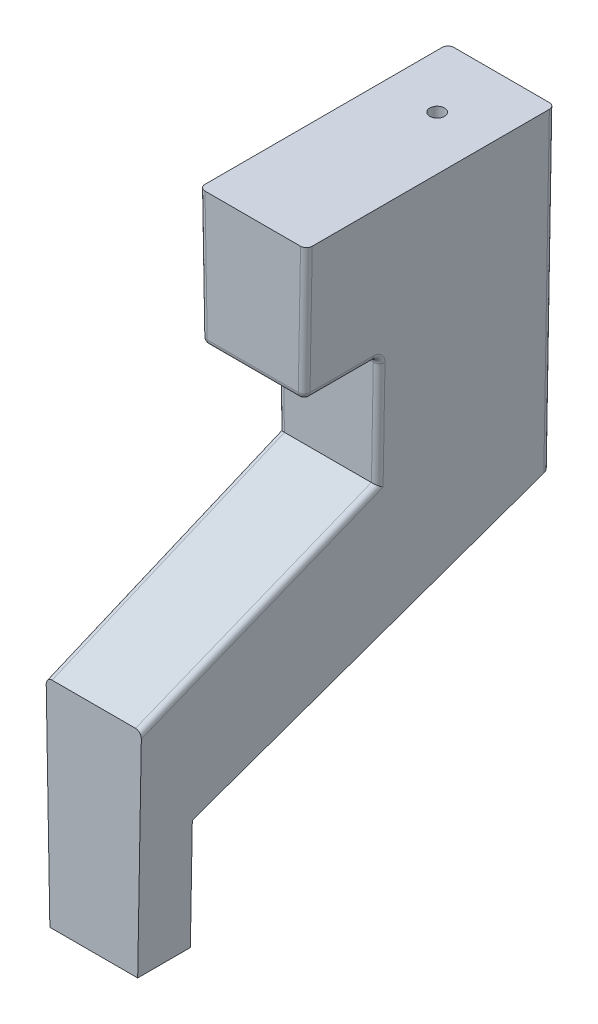
from build123d import *

# Parameters (mm, degrees)
BOSS_EXTRUDE1_DEPTH = 1.5
DRAFT4_ANGLE        = -1
FILLET1_R           = 0.1
SKETCH5_R           = 0.125
CUT_EXTRUDE1_DEPTH  = 2.5


with BuildPart() as part:
    # Sketch1 → Boss-Extrude1 (new body)
    with BuildSketch(Plane(origin=(0, 0, 0), x_dir=(0, 0, -1), z_dir=(1, 0, 0))):
        Polygon((0.9, 1.9), (0.9, 0), (0, 0), (0, 3.674994058), (4, 5.325119328), (4, 7.218922126), (2.71583546, 7.218922126), (2.71583546, 9.5), (6.966077176, 9.5), (6.966077176, 4.107871531), align=None)
    extrude(amount=BOSS_EXTRUDE1_DEPTH)

    # Draft4
    draft4_faces = [part.faces().sort_by_distance(p)[0] for p in [
        (0, 5.526450361, -4.018047871),
        (1.5, 5.526450361, -4.018047871),
    ]]
    draft(draft4_faces, Plane.ZX, DRAFT4_ANGLE)

    # Fillet1
    fillet1_edges = [part.edges().sort_by_distance(p)[0] for p in [
        (1.609478529, 6.272020727, -4),
        (-0.078548782, 4.500056693, -2),
        (-0.109478529, 6.272020727, -4),
        (-0.126006754, 7.218922126, -3.35791773),
        (-0.145914936, 8.359461063, -2.71583546),
        (1.578548782, 4.500056693, -2),
        (0.75, 7.218922126, -4),
        (0.75, 7.218922126, -2.71583546),
        (1.618763141, 6.803935765, -6.966077176),
        (1.645914936, 8.359461063, -2.71583546),
        (1.626006754, 7.218922126, -3.35791773),
        (-0.118763141, 6.803935765, -6.966077176),
    ]]
    fillet(fillet1_edges, radius=FILLET1_R)

    # Sketch5 → Cut-Extrude1 (cut)
    with BuildSketch(Plane(origin=(0, 9.5, 0), x_dir=(1, 0, 0), z_dir=(0, 1, 0))):
        with Locations((0.75, 5.866077176)):
            Circle(SKETCH5_R)
    extrude(amount=-CUT_EXTRUDE1_DEPTH, mode=Mode.SUBTRACT)


solid = part.part
